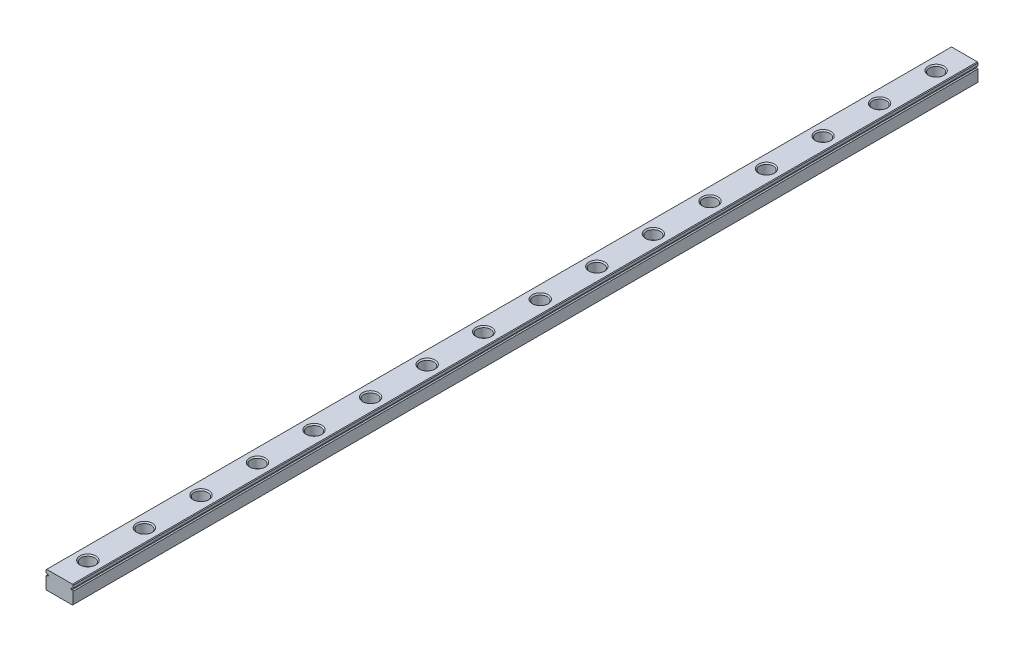
from build123d import *

# Parameters (mm, degrees)
BOSS_EXTRUDE1_DEPTH = 400
CHAMFER1_SIZE       = 0.3
LPATTERN1_COUNT     = 16
LPATTERN1_PITCH     = 25


with BuildPart() as part:
    # Sketch1 → Boss-Extrude1 (new body)
    with BuildSketch(Plane.XY):
        with BuildLine():
            Line((-6, 4), (6, 4))
            Line((6, 4), (6, 2.75))
            Line((6, 2.75), (6, 2.559016994))
            ThreePointArc((6, 2.559016994), (5.706107374, 2.475528258), (5.5, 2.25))
            Line((5.5, 2.25), (5, 2.25))
            Line((5, 2.25), (5, 1.75))
            Line((5, 1.75), (5.5, 1.75))
            ThreePointArc((5.5, 1.75), (5.706107374, 1.524471742), (6, 1.440983006))
            Line((6, 1.440983006), (6, 1.25))
            Line((6, 1.25), (6, -4))
            Line((6, -4), (-6, -4))
            Line((-6, -4), (-6, 1.25))
            Line((-6, 1.25), (-6, 1.440983006))
            ThreePointArc((-6, 1.440983006), (-5.706107374, 1.524471742), (-5.5, 1.75))
            Line((-5.5, 1.75), (-5, 1.75))
            Line((-5, 1.75), (-5, 2.25))
            Line((-5, 2.25), (-5.5, 2.25))
            ThreePointArc((-5.5, 2.25), (-5.706107374, 2.475528258), (-6, 2.559016994))
            Line((-6, 2.559016994), (-6, 2.75))
            Line((-6, 2.75), (-6, 4))
        make_face()
    extrude(amount=BOSS_EXTRUDE1_DEPTH)

    # Chamfer1
    chamfer1_edges = [part.edges().sort_by_distance(p)[0] for p in [
        (-6, 4, 200),
        (6, 4, 200),
        (6, -4, 200),
        (-6, -4, 200),
    ]]
    chamfer(chamfer1_edges, length=CHAMFER1_SIZE)

    # Sketch3 → M3 六角承窩頭蓋螺釘的柱孔1 (revolve, cut)
    with BuildSketch(Plane(origin=(0, 4, 12.5), x_dir=(0, 0, 1), z_dir=(1, 0, 0))):
        Polygon((0, 0), (0, 8), (2, 8), (1.75, 7.75), (1.75, 4.5), (3, 4.5), (3, 0.5), (3.5, 0), align=None)
    hole_wizard_m3_1 = revolve(axis=Axis((0, 10.35, 12.5), (0, -1, 0)), mode=Mode.SUBTRACT)

    # LPattern1: M3 六角承窩頭蓋螺釘的柱孔1 ×16
    with Locations(*[(0, 0, i * LPATTERN1_PITCH) for i in range(1, LPATTERN1_COUNT)]):
        add(hole_wizard_m3_1, mode=Mode.SUBTRACT)


solid = part.part
